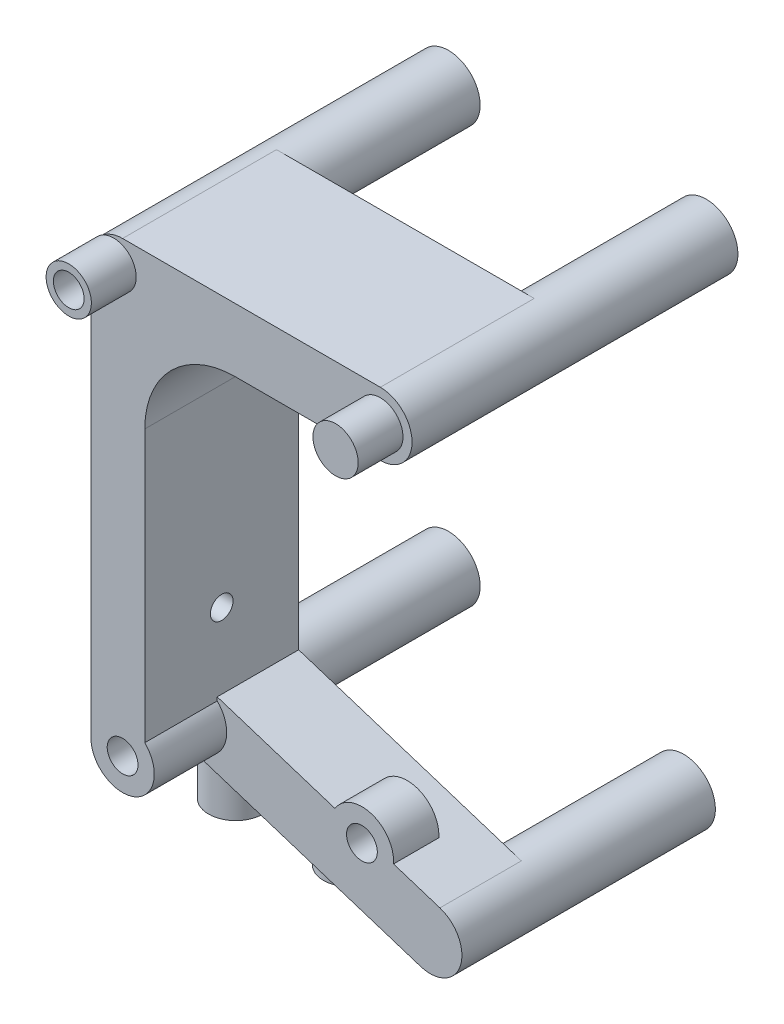
from build123d import *

# Parameters (mm, degrees)
SKIZZE1_R                         = 3.5
AUFSATZ_LINEAR_AUSTRAGEN1_DEPTH   = 36
AUFSATZ_LINEAR_AUSTRAGEN1_2_DEPTH = 36
AUFSATZ_LINEAR_AUSTRAGEN1_3_DEPTH = 36
AUFSATZ_LINEAR_AUSTRAGEN1_4_DEPTH = 36
AUFSATZ_LINEAR_AUSTRAGEN2_DEPTH   = 17
SKIZZE3_R                         = 1.25
SCHNITT_LINEAR_AUSTRAGEN1_DEPTH   = 6.95
SKIZZE4_R                         = 2.1
SCHNITT_LINEAR_AUSTRAGEN2_DEPTH   = 4.2
SCHNITT_LINEAR_AUSTRAGEN3_DEPTH   = 8
VERRUNDUNG1_R                     = 10
SKIZZE11_R                        = 3
AUFSATZ_LINEAR_AUSTRAGEN3_DEPTH   = 9.47
SCHNITT_LINEAR_AUSTRAGEN7_DEPTH   = 29
SKIZZE13_R                        = 3.5
AUFSATZ_LINEAR_AUSTRAGEN4_DEPTH   = 5
SKIZZE14_R                        = 1.7
SCHNITT_LINEAR_AUSTRAGEN8_DEPTH   = 4
SKIZZE15_R                        = 1.7
SCHNITT_LINEAR_AUSTRAGEN9_DEPTH   = 4
SKIZZE16_R                        = 1.7
SCHNITT_LINEAR_AUSTRAGEN10_DEPTH  = 4
SKIZZE20_R                        = 2.5
AUFSATZ_LINEAR_AUSTRAGEN5_DEPTH   = 4.95
SKIZZE21_R                        = 1.7
SCHNITT_LINEAR_AUSTRAGEN13_DEPTH  = 4


with BuildPart() as part:
    # Skizze1 → Aufsatz-Linear austragen1 (new body)
    with BuildSketch(Plane.XY):
        with Locations((50.05, -80.201897)):
            Circle(SKIZZE1_R)
    extrude(amount=AUFSATZ_LINEAR_AUSTRAGEN1_DEPTH)



with BuildPart() as body_2:
    # Skizze1 → Aufsatz-Linear austragen1 2 (new body)
    with BuildSketch(Plane.XY):
        with Locations((50.05, -34.181906)):
            Circle(SKIZZE1_R)
    extrude(amount=AUFSATZ_LINEAR_AUSTRAGEN1_2_DEPTH)


with BuildPart() as body_3:
    # Skizze1 → Aufsatz-Linear austragen1 3 (new body)
    with BuildSketch(Plane.XY):
        with Locations((78.525, -34.181906)):
            Circle(SKIZZE1_R)
    extrude(amount=AUFSATZ_LINEAR_AUSTRAGEN1_3_DEPTH)


with BuildPart() as body_4:
    # Skizze1 → Aufsatz-Linear austragen1 4 (new body)
    with BuildSketch(Plane.XY):
        with Locations((76.035534, -88.535534)):
            Circle(SKIZZE1_R)
    extrude(amount=AUFSATZ_LINEAR_AUSTRAGEN1_4_DEPTH)


with BuildPart() as part_1:
    add(part.part)

    add(body_2.part)  # Aufsatz-Linear austragen2 merges body 2

    add(body_3.part)  # Aufsatz-Linear austragen2 merges body 3

    add(body_4.part)  # Aufsatz-Linear austragen2 merges body 4
    # Skizze2 → Aufsatz-Linear austragen2 (add)
    with BuildSketch(Plane.XY.offset(36)):
        with BuildLine():
            Line((50.05, -30.681906), (78.525, -30.681906))
            ThreePointArc((78.525, -30.681906), (82.025, -34.181906), (78.525, -37.681906))
            Line((78.525, -37.681906), (52.5, -37.681906))
            Line((52.5, -37.681906), (52.5, -77.312036))
            Line((52.5, -77.312036), (77.104374, -85.20273))
            ThreePointArc((77.104374, -85.20273), (79.368338, -89.604374), (74.966694, -91.868338))
            Line((74.966694, -91.868338), (48.98116, -83.534701))
            ThreePointArc((48.98116, -83.534701), (47.222374, -82.264549), (46.55, -80.201897))
            Line((46.55, -80.201897), (46.55, -34.181906))
            ThreePointArc((46.55, -34.181906), (47.575126, -31.707032), (50.05, -30.681906))
        make_face()
    extrude(amount=-AUFSATZ_LINEAR_AUSTRAGEN2_DEPTH)

    # Skizze3 → Schnitt-Linear austragen1 (cut, through all)
    with BuildSketch(Plane(origin=(52.5, 0, 0), x_dir=(0, 0, -1), z_dir=(1, 0, 0))):
        with Locations((-27.5, -69)):
            Circle(SKIZZE3_R)
    extrude(amount=-SCHNITT_LINEAR_AUSTRAGEN1_DEPTH, mode=Mode.SUBTRACT)

    # Skizze4 → Schnitt-Linear austragen2 (cut)
    with BuildSketch(Plane(origin=(0, 0, 0), x_dir=(-1, 0, 0), z_dir=(0, 0, -1))):
        with Locations((-78.525, -34.181906)):
            Circle(SKIZZE4_R)
        with Locations((-50.05, -34.181906)):
            Circle(SKIZZE4_R)
        with Locations((-50.05, -80.201897)):
            Circle(SKIZZE4_R)
        with Locations((-76.035534, -88.535534)):
            Circle(SKIZZE4_R)
    extrude(amount=-SCHNITT_LINEAR_AUSTRAGEN2_DEPTH, mode=Mode.SUBTRACT)

    # Skizze5 → Schnitt-Linear austragen3 (cut)
    with BuildSketch(Plane.XY.offset(36)):
        with BuildLine():
            Line((74.966694, -91.868338), (48.98116, -83.534701))
            ThreePointArc((48.98116, -83.534701), (53.046805, -82.009978), (52.5, -77.702397))
            Line((52.5, -77.702397), (52.5, -77.312036))
            Line((52.5, -77.312036), (77.104374, -85.20273))
            ThreePointArc((77.104374, -85.20273), (79.368338, -89.604374), (74.966694, -91.868338))
        make_face()
    extrude(amount=-SCHNITT_LINEAR_AUSTRAGEN3_DEPTH, mode=Mode.SUBTRACT)

    # Verrundung1
    verrundung1_edges = [part_1.edges().sort_by_distance(p)[0] for p in [
        (52.5, -37.681906, 27.5),
    ]]
    fillet(verrundung1_edges, radius=VERRUNDUNG1_R)

    # Skizze11 → Aufsatz-Linear austragen3 (add)
    with BuildSketch(Plane(origin=(0, -89.47, 0), x_dir=(1, 0, 0), z_dir=(0, 1, 0))):
        with Locations((51.09, -24.54)):
            Circle(SKIZZE11_R)
        with Locations((63.79, -24.54)):
            Circle(SKIZZE11_R)
    extrude(amount=AUFSATZ_LINEAR_AUSTRAGEN3_DEPTH)

    # Skizze12 → Schnitt-Linear austragen7 (cut, through all)
    with BuildSketch(Plane.XY.offset(28)):
        Polygon((60.881478, -80), (66.79, -81.89488), (66.79, -80), align=None)
    extrude(amount=-SCHNITT_LINEAR_AUSTRAGEN7_DEPTH, mode=Mode.SUBTRACT)

    # Skizze13 → Aufsatz-Linear austragen4 (add)
    with BuildSketch(Plane.XY.offset(28)):
        with Locations((68.49, -83.32)):
            Circle(SKIZZE13_R)
    extrude(amount=-AUFSATZ_LINEAR_AUSTRAGEN4_DEPTH)

    # Skizze14 → Schnitt-Linear austragen8 (cut)
    with BuildSketch(Plane.XY.offset(28)):
        with Locations((68.49, -83.32)):
            Circle(SKIZZE14_R)
    extrude(amount=-SCHNITT_LINEAR_AUSTRAGEN8_DEPTH, mode=Mode.SUBTRACT)

    # Skizze15 → Schnitt-Linear austragen9 (cut)
    with BuildSketch(Plane.XY.offset(36)):
        with Locations((50.05, -80.201897)):
            Circle(SKIZZE15_R)
    extrude(amount=-SCHNITT_LINEAR_AUSTRAGEN9_DEPTH, mode=Mode.SUBTRACT)

    # Skizze16 → Schnitt-Linear austragen10 (cut)
    with BuildSketch(Plane(origin=(0, -89.47, 0), x_dir=(-1, 0, 0), z_dir=(0, -1, 0))):
        with Locations((-51.09, -24.54)):
            Circle(SKIZZE16_R)
        with Locations((-63.79, -24.54)):
            Circle(SKIZZE16_R)
    extrude(amount=-SCHNITT_LINEAR_AUSTRAGEN10_DEPTH, mode=Mode.SUBTRACT)

    # Skizze20 → Aufsatz-Linear austragen5 (add)
    with BuildSketch(Plane.XY.offset(36)):
        with Locations((49.05, -33.631906)):
            Circle(SKIZZE20_R)
        with Locations((78.525, -34.181906)):
            Circle(SKIZZE20_R)
    extrude(amount=AUFSATZ_LINEAR_AUSTRAGEN5_DEPTH)

    # Skizze21 → Schnitt-Linear austragen13 (cut)
    with BuildSketch(Plane.XY.offset(40.95)):
        with Locations((49.05, -33.631906)):
            Circle(SKIZZE21_R)
    extrude(amount=-SCHNITT_LINEAR_AUSTRAGEN13_DEPTH, mode=Mode.SUBTRACT)


solid = part_1.part
